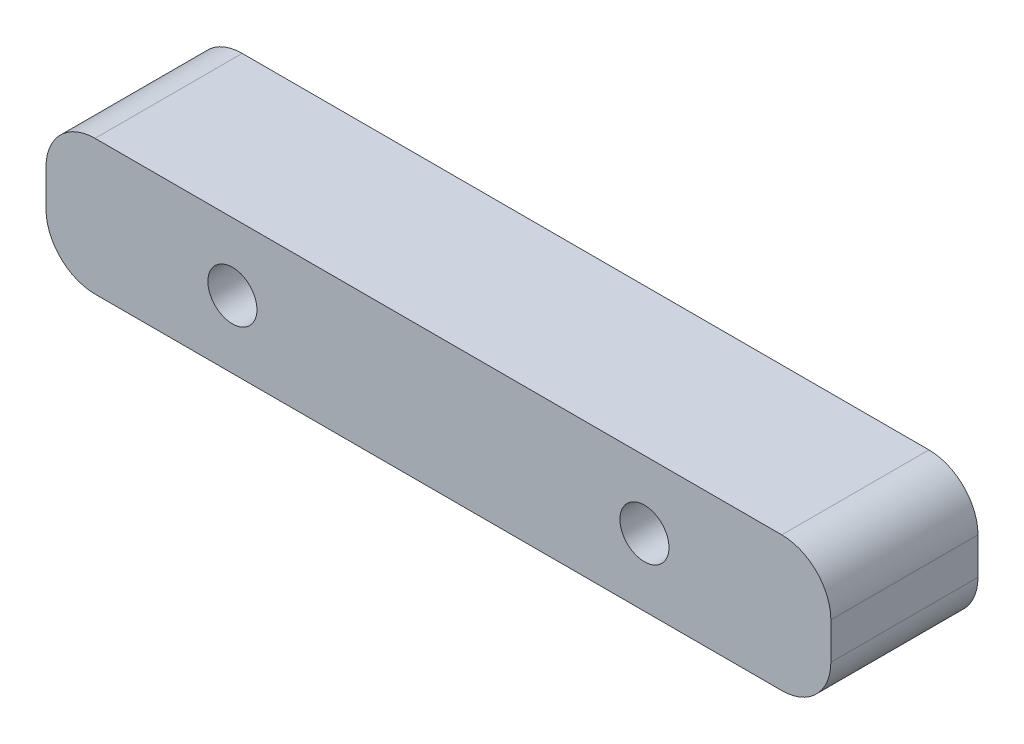
from build123d import *

# Parameters (mm, degrees)
BOSS_EXTRUDE1_DEPTH = 15
SKETCH2_R           = 2.5
CUT_EXTRUDE1_DEPTH  = 16


with BuildPart() as part:
    # Sketch1 → Boss-Extrude1 (new body)
    with BuildSketch(Plane.XY):
        with BuildLine():
            Line((-35, 6.875), (35, 6.875))
            ThreePointArc((35, 6.875), (38.535533906, 5.410533906), (40, 1.875))
            Line((40, 1.875), (40, -1.875))
            ThreePointArc((40, -1.875), (38.535533906, -5.410533906), (35, -6.875))
            Line((35, -6.875), (-35, -6.875))
            ThreePointArc((-35, -6.875), (-38.535533906, -5.410533906), (-40, -1.875))
            Line((-40, -1.875), (-40, 1.875))
            ThreePointArc((-40, 1.875), (-38.535533906, 5.410533906), (-35, 6.875))
        make_face()
    extrude(amount=BOSS_EXTRUDE1_DEPTH)

    # Sketch2 → Cut-Extrude1 (cut, through all)
    with BuildSketch(Plane.XY.offset(15)):
        with Locations((-21, 0)):
            Circle(SKETCH2_R)
        with Locations((21, 0)):
            Circle(SKETCH2_R)
    extrude(amount=-CUT_EXTRUDE1_DEPTH, mode=Mode.SUBTRACT)


solid = part.part
